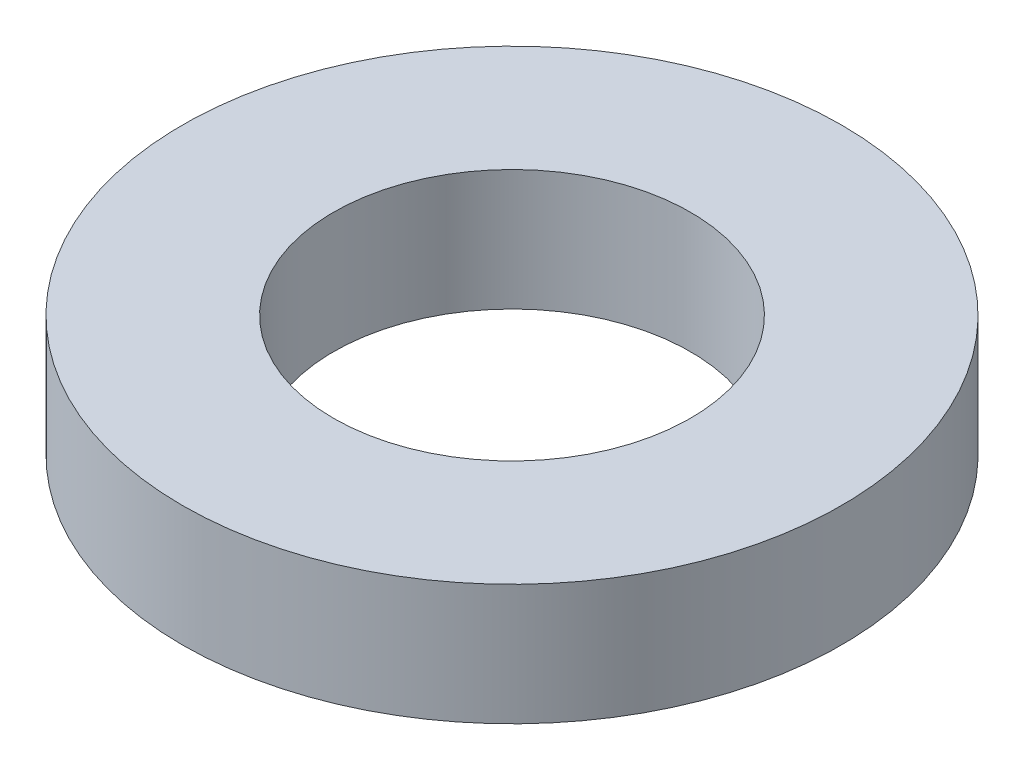
from build123d import *

# Parameters (mm, degrees)
SKETCH2_R           = 60
SKETCH2_R_2         = 32.5
BOSS_EXTRUDE1_DEPTH = 22


with BuildPart() as part:
    # Sketch2 → Boss-Extrude1 (new body)
    with BuildSketch(Plane(origin=(0, 0, 0), x_dir=(1, 0, 0), z_dir=(0, 1, 0))):
        Circle(SKETCH2_R)
        Circle(SKETCH2_R_2, mode=Mode.SUBTRACT)
    extrude(amount=BOSS_EXTRUDE1_DEPTH)


solid = part.part
